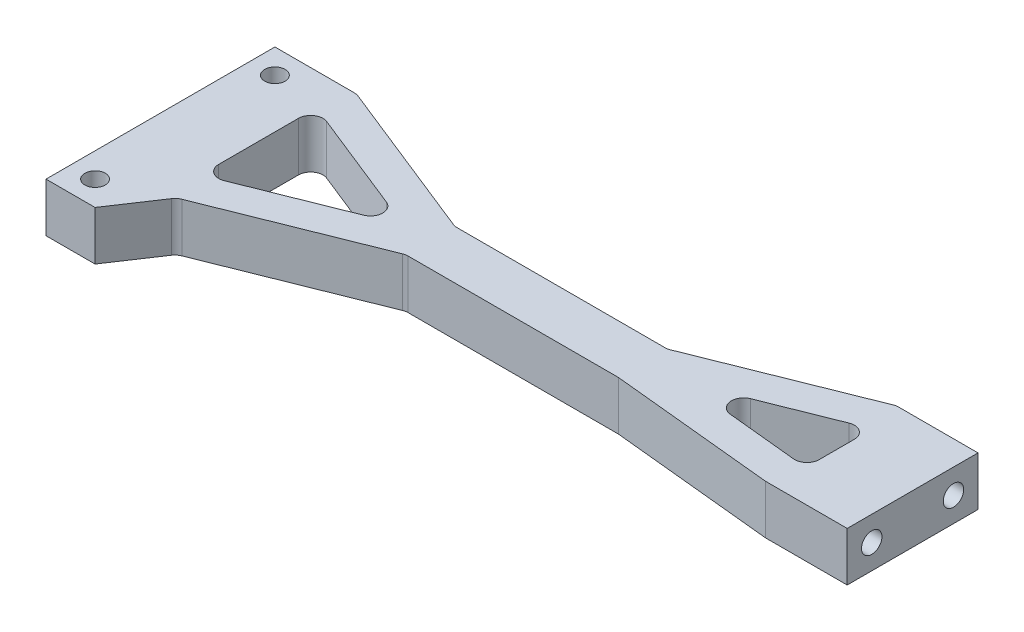
from build123d import *

# Parameters (mm, degrees)
BOSS_EXTRUDE1_DEPTH         = 6
TAP_DRILL_FOR_M3_TAP3_D     = 2.5
TAP_DRILL_FOR_M3_TAP3_DEPTH = 10
TAP_DRILL_FOR_M3_TAP3_TIP   = 0.751075774
TAP_DRILL_FOR_M3_TAP2_D     = 2.5
TAP_DRILL_FOR_M3_TAP2_DEPTH = 8
TAP_DRILL_FOR_M3_TAP2_TIP   = 0.751075774
TAP_DRILL_FOR_M3_TAP1_D     = 2.5
TAP_DRILL_FOR_M3_TAP1_DEPTH = 8
TAP_DRILL_FOR_M3_TAP1_TIP   = 0.751075774
FILLET1_R                   = 1.5


with BuildPart() as part:
    # Sketch2 → Boss-Extrude1 (new body)
    with BuildSketch(Plane(origin=(0, 0, 0), x_dir=(1, 0, 0), z_dir=(0, 1, 0))):
        Polygon((56, -8), (76, 0), (86, 0), (86, -16), (76, -16), (56, -14), (30, -14), (10, -22), (6, -28), (0, -28), (0, 0), (10, 0), (30, -8), align=None)
        Polygon((9, -3.908131846), (26.729670386, -11), (9, -18.091868154), align=None, mode=Mode.SUBTRACT)
        Polygon((60.656164188, -10.44566617), (77, -12.080049752), (77, -3.908131846), align=None, mode=Mode.SUBTRACT)
    extrude(amount=BOSS_EXTRUDE1_DEPTH)

    # Tap Drill for M3 Tap3
    with Locations(Plane(origin=(0, 6, 0), x_dir=(1, 0, 0), z_dir=(0, 1, 0))):
        with Locations((3, -3), (3, -25)):
            Hole(TAP_DRILL_FOR_M3_TAP3_D / 2, depth=TAP_DRILL_FOR_M3_TAP3_DEPTH)
            with Locations((0, 0, -(TAP_DRILL_FOR_M3_TAP3_DEPTH + TAP_DRILL_FOR_M3_TAP3_TIP / 2))):  # 118° drill point
                Cone(0, TAP_DRILL_FOR_M3_TAP3_D / 2, TAP_DRILL_FOR_M3_TAP3_TIP, mode=Mode.SUBTRACT)

    # Tap Drill for M3 Tap2
    with Locations(Plane(origin=(86, 0.779165189, 7.640466368), x_dir=(0, 0, -1), z_dir=(1, 0, 0))):
        with Locations((-5.359533632, 2.220834811), (4.640466368, 2.220834811)):
            Hole(TAP_DRILL_FOR_M3_TAP2_D / 2, depth=TAP_DRILL_FOR_M3_TAP2_DEPTH)
            with Locations((0, 0, -(TAP_DRILL_FOR_M3_TAP2_DEPTH + TAP_DRILL_FOR_M3_TAP2_TIP / 2))):  # 118° drill point
                Cone(0, TAP_DRILL_FOR_M3_TAP2_D / 2, TAP_DRILL_FOR_M3_TAP2_TIP, mode=Mode.SUBTRACT)

    # Tap Drill for M3 Tap1
    with Locations(Plane.ZY):
        with Locations((8, 3), (18, 3)):
            Hole(TAP_DRILL_FOR_M3_TAP1_D / 2, depth=TAP_DRILL_FOR_M3_TAP1_DEPTH)
            with Locations((0, 0, -(TAP_DRILL_FOR_M3_TAP1_DEPTH + TAP_DRILL_FOR_M3_TAP1_TIP / 2))):  # 118° drill point
                Cone(0, TAP_DRILL_FOR_M3_TAP1_D / 2, TAP_DRILL_FOR_M3_TAP1_TIP, mode=Mode.SUBTRACT)

    # Fillet1
    fillet1_edges = [part.edges().sort_by_distance(p)[0] for p in [
        (10, 3, 0),
        (30, 3, 8),
        (56, 3, 8),
        (76, 3, 0),
        (30, 3, 14),
        (10, 3, 22),
        (9, 3, 18.091868154),
        (26.729670386, 3, 11),
        (9, 3, 3.908131846),
        (77, 3, 3.908131846),
        (60.656164188, 3, 10.44566617),
        (77, 3, 12.080049752),
    ]]
    fillet(fillet1_edges, radius=FILLET1_R)


solid = part.part
